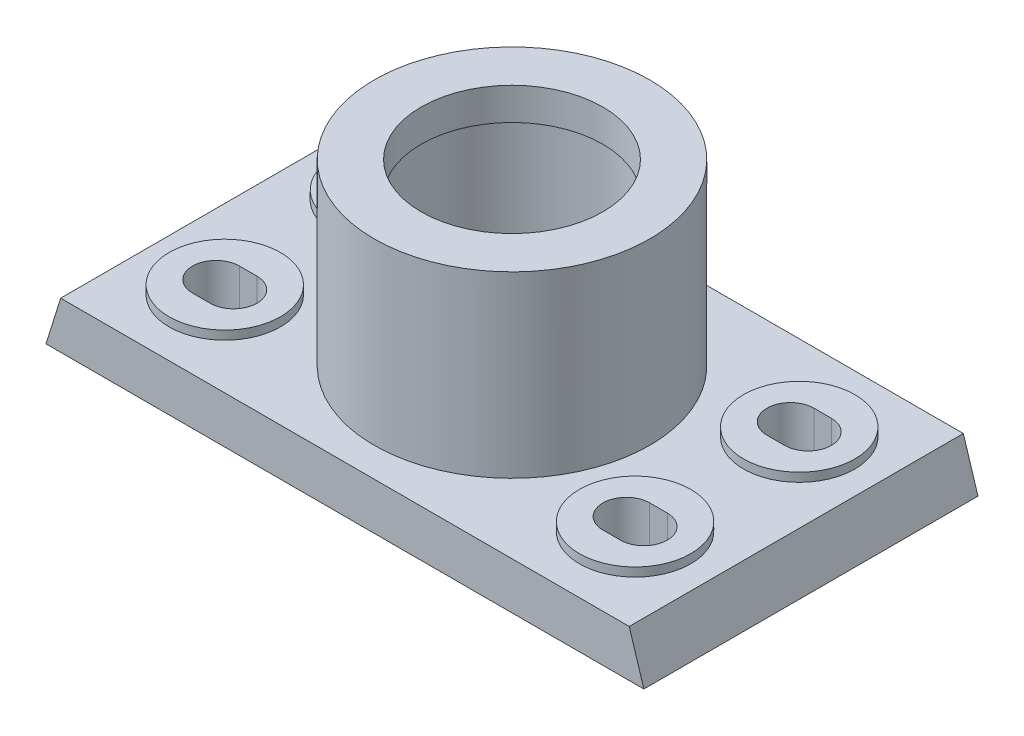
from build123d import *

# Parameters (mm, degrees)
BOSS_EXTRUDE1_DEPTH  = 57
SKETCH2_W            = 85.5
SKETCH2_H            = 94
CUT_EXTRUDE1_DEPTH   = 3
SKETCH4_R            = 47
BOSS_EXTRUDE2_DEPTH  = 61
SKETCH6_R            = 19
BOSS_EXTRUDE4_DEPTH  = 3
CUT_EXTRUDE2_DEPTH   = 20
MIRROR4_COPY_1_DEPTH = 20
SKETCH10_R           = 31
CUT_EXTRUDE3_DEPTH   = 11
SKETCH11_R           = 32.5
CUT_EXTRUDE4_DEPTH   = 37
SKETCH12_R           = 31
CUT_EXTRUDE5_DEPTH   = 13
SKETCH13_R           = 1.5
CUT_EXTRUDE6_DEPTH   = 5


with BuildPart() as part:
    # Sketch1 → Boss-Extrude1 (new body, symmetric)
    with BuildSketch(Plane.XY):
        Polygon((-102, 0), (102, 0), (97, 16), (-97, 16), align=None)
    extrude(amount=BOSS_EXTRUDE1_DEPTH, both=True)

    # Sketch2 → Cut-Extrude1 (cut)
    with BuildSketch(Plane.XZ):
        with Locations((-49.25, 0)):
            Rectangle(SKETCH2_W, SKETCH2_H)
    cut_extrude1 = extrude(amount=-CUT_EXTRUDE1_DEPTH, mode=Mode.SUBTRACT)

    # Mirror1: Cut-Extrude1 across plane
    add(cut_extrude1.mirror(Plane(origin=(0, 0, 0), x_dir=(0, 0, 1), z_dir=(1, 0, 0))), mode=Mode.SUBTRACT)

    # Sketch4 → Boss-Extrude2 (add)
    with BuildSketch(Plane(origin=(0, 16, 0), x_dir=(1, 0, 0), z_dir=(0, 1, 0))):
        with Locations(Location((0, 0, 0), (0, 0, 90))):  # turned: the seam where the file's is
            Circle(SKETCH4_R)
    extrude(amount=BOSS_EXTRUDE2_DEPTH)

    # Sketch6 → Boss-Extrude4 (add)
    with BuildSketch(Plane(origin=(0, 16, 0), x_dir=(1, 0, 0), z_dir=(0, 1, 0))):
        with Locations(Location((70, -28, 0), (0, 0, 90))):  # turned: the seam where the file's is
            Circle(SKETCH6_R)
        with Locations(Location((70, 28, 0), (0, 0, 90))):  # turned: the seam where the file's is
            Circle(SKETCH6_R)
    boss_extrude4 = extrude(amount=BOSS_EXTRUDE4_DEPTH)

    # Sketch9 → Cut-Extrude2 (cut, through all)
    with BuildSketch(Plane(origin=(0, 19, 0), x_dir=(1, 0, 0), z_dir=(0, 1, 0))):
        with BuildLine():
            Line((73, -36), (67, -36))
            ThreePointArc((67, -36), (59, -28), (67, -20))
            Line((67, -20), (73, -20))
            ThreePointArc((73, -20), (81, -28), (73, -36))
        make_face()
    cut_extrude2 = extrude(amount=-CUT_EXTRUDE2_DEPTH, mode=Mode.SUBTRACT)

    # Mirror2: Boss-Extrude4 across plane
    add(boss_extrude4.mirror(Plane(origin=(0, 0, 0), x_dir=(0, 0, 1), z_dir=(1, 0, 0))))

    # Mirror3: Cut-Extrude2 across plane
    add(cut_extrude2.mirror(Plane.XY), mode=Mode.SUBTRACT)

    # Mirror4: Cut-Extrude2 across plane
    add(cut_extrude2.mirror(Plane(origin=(0, 0, 0), x_dir=(0, 0, 1), z_dir=(1, 0, 0))), mode=Mode.SUBTRACT)

    # Mirror4 copy 1 sketch → Mirror4 copy 1 (cut, through all)
    with BuildSketch(Plane(origin=(0, 19, 0), x_dir=(-1, 0, 0), z_dir=(0, 1, 0))):
        with BuildLine():
            Line((73, -36), (67, -36))
            ThreePointArc((67, -36), (59, -28), (67, -20))
            Line((67, -20), (73, -20))
            ThreePointArc((73, -20), (81, -28), (73, -36))
        make_face()
    extrude(amount=-MIRROR4_COPY_1_DEPTH, mode=Mode.SUBTRACT)

    # Sketch10 → Cut-Extrude3 (cut)
    with BuildSketch(Plane(origin=(0, 77, 0), x_dir=(1, 0, 0), z_dir=(0, 1, 0))):
        with Locations(Location((0, 0, 0), (0, 0, 270))):  # turned: the seam where the file's is
            Circle(SKETCH10_R)
    extrude(amount=-CUT_EXTRUDE3_DEPTH, mode=Mode.SUBTRACT)

    # Sketch11 → Cut-Extrude4 (cut)
    with BuildSketch(Plane(origin=(0, 66, 0), x_dir=(1, 0, 0), z_dir=(0, 1, 0))):
        with Locations(Location((0, 0, 0), (0, 0, 270))):  # turned: the seam where the file's is
            Circle(SKETCH11_R)
    extrude(amount=-CUT_EXTRUDE4_DEPTH, mode=Mode.SUBTRACT)

    # Sketch12 → Cut-Extrude5 (cut)
    with BuildSketch(Plane(origin=(0, 29, 0), x_dir=(1, 0, 0), z_dir=(0, 1, 0))):
        with Locations(Location((0, 0, 0), (0, 0, 270))):  # turned: the seam where the file's is
            Circle(SKETCH12_R)
    extrude(amount=-CUT_EXTRUDE5_DEPTH, mode=Mode.SUBTRACT)

    # Sketch13 → Cut-Extrude6 (cut)
    with BuildSketch(Plane(origin=(0, 16, 0), x_dir=(1, 0, 0), z_dir=(0, 1, 0))):
        with Locations(Location((22, 0, 0), (0, 0, 270))):  # turned: the seam where the file's is
            Circle(SKETCH13_R)
    extrude(amount=-CUT_EXTRUDE6_DEPTH, mode=Mode.SUBTRACT)


solid = part.part
